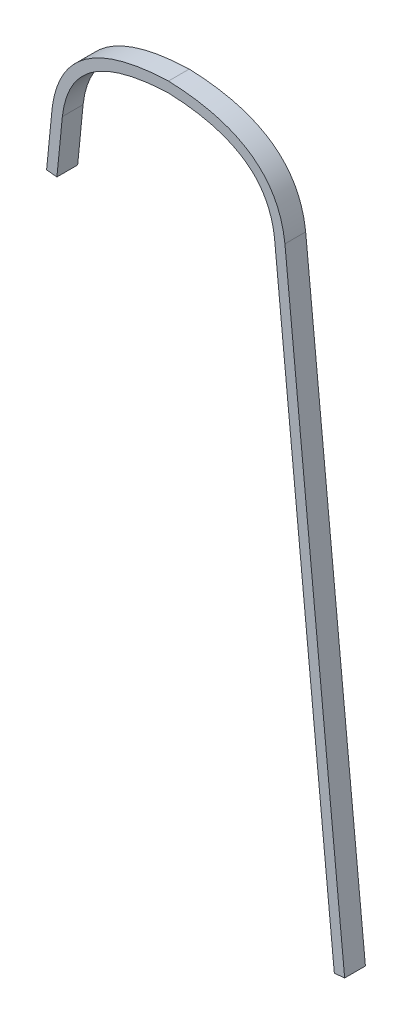
from build123d import *

# Parameters (mm, degrees)
BOSS_EXTRUDE1_DEPTH = 19.05


with BuildPart() as part:
    # Sketch1 → Boss-Extrude1 (new body)
    with BuildSketch(Plane.XY):
        with BuildLine():
            Line((152.224173193, 179.795336584), (97.403993572, 735.828587024))
            add(Edge.make_bspline(
                [(0, 803.26908628), (0.979817658, 803.233925105), (2.950075123, 803.151909058), (6.800362849, 802.946009068), (11.504912112, 802.608232022), (16.957304332, 802.075979486), (23.975792063, 801.198424891), (32.273128008, 799.790052384), (41.46699497, 797.614109593), (49.89784204, 794.967332344), (60.129456963, 790.832450746), (71.050790712, 784.572420078), (79.648241417, 776.932392043), (85.274313562, 769.943199813), (88.89525226, 764.228265264), (91.933130485, 758.00316425), (93.979934001, 752.359286407), (95.321414001, 747.554999291), (96.177362738, 743.805316844), (96.764020616, 740.553537606), (97.155379667, 737.881968465), (97.326205951, 736.51096636), (97.403993572, 735.828587024)],
                knots=[0.000508173, 0.000508173, 0.000508173, 0.000508173, 0.016098161, 0.031688149, 0.062868125, 0.094048101, 0.125228077, 0.187588029, 0.249947981, 0.312307933, 0.374667885, 0.499387789, 0.624107693, 0.686467645, 0.748827597, 0.811187549, 0.873547501, 0.904727477, 0.935907453, 0.967087429, 0.982677417, 0.998267405, 0.998267405, 0.998267405, 0.998267405], degree=3))
            add(Edge.make_bspline(
                [(-97.403993572, 735.828587024), (-97.326205951, 736.51096636), (-97.155379667, 737.881968465), (-96.764020616, 740.553537606), (-96.177362738, 743.805316844), (-95.321414001, 747.554999291), (-93.979934001, 752.359286407), (-91.933130485, 758.00316425), (-88.89525226, 764.228265264), (-85.274313562, 769.943199813), (-79.648241417, 776.932392043), (-71.050790712, 784.572420078), (-60.129456963, 790.832450746), (-49.89784204, 794.967332344), (-41.46699497, 797.614109593), (-32.273128008, 799.790052384), (-23.975792063, 801.198424891), (-16.957304332, 802.075979486), (-11.504912112, 802.608232022), (-6.800362849, 802.946009068), (-2.950075123, 803.151909058), (-0.979817658, 803.233925105), (0, 803.26908628)],
                knots=[0.000508173, 0.000508173, 0.000508173, 0.000508173, 0.016098161, 0.031688149, 0.062868125, 0.094048101, 0.125228077, 0.187588029, 0.249947981, 0.312307933, 0.374667885, 0.499387789, 0.624107693, 0.686467645, 0.748827597, 0.811187549, 0.873547501, 0.904727477, 0.935907453, 0.967087429, 0.982677417, 0.998267405, 0.998267405, 0.998267405, 0.998267405], degree=3))
            Line((-97.403993572, 735.828587024), (-102.381323889, 685.344236665))
            Line((-102.381323889, 685.344236665), (-111.860365766, 686.278790089))
            Line((-111.860365766, 686.278790089), (-106.876080835, 736.833680097))
            add(Edge.make_bspline(
                [(-106.876080835, 736.833680097), (-98.655564568, 809.385111394), (0, 812.8)],
                knots=[0, 0, 0, 1, 1, 1], degree=2))
            add(Edge.make_bspline(
                [(106.876080835, 736.833680097), (98.655564568, 809.385111394), (0, 812.8)],
                knots=[0, 0, 0, 1, 1, 1], degree=2))
            Line((106.876080835, 736.833680097), (161.70321507, 180.729890008))
            Line((161.70321507, 180.729890008), (152.224173193, 179.795336584))
        make_face()
    extrude(amount=BOSS_EXTRUDE1_DEPTH)


solid = part.part
